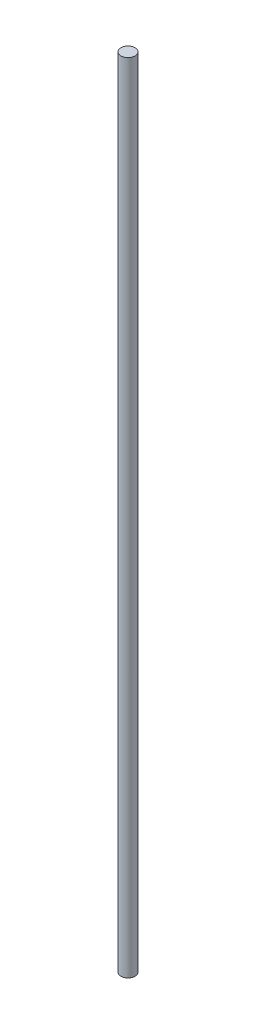
from build123d import *

# Parameters (mm, degrees)
CROQUIS1_R                 = 1.524
SALIENTE_EXTRUIR1_DEPTH    = 177.8
CROQUIS2_W                 = 3.048
CROQUIS2_H                 = 6.738530463
CORTAR_EXTRUIR1_DEPTH      = 8.128
CORTAR_EXTRUIR1_DEPTH_BACK = 7.62


with BuildPart() as part:
    # Croquis1 → Saliente-Extruir1 (new body)
    with BuildSketch(Plane(origin=(0, 0, 0), x_dir=(1, 0, 0), z_dir=(0, 1, 0))):
        Circle(CROQUIS1_R)
    extrude(amount=SALIENTE_EXTRUIR1_DEPTH)

    # Croquis2 → Cortar-Extruir1 (cut, two sides)
    with BuildSketch(Plane(origin=(0, 0, 0), x_dir=(0, 0, -1), z_dir=(1, 0, 0))) as cortar_extruir1_sk:
        with Locations((0, 174.430734769)):
            Rectangle(CROQUIS2_W, CROQUIS2_H)
    extrude(amount=CORTAR_EXTRUIR1_DEPTH, mode=Mode.SUBTRACT)
    extrude(cortar_extruir1_sk.sketch, amount=-CORTAR_EXTRUIR1_DEPTH_BACK, mode=Mode.SUBTRACT)


solid = part.part
